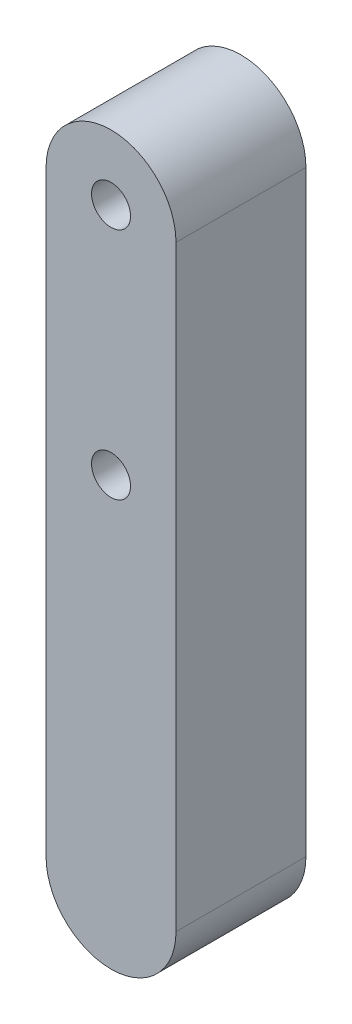
from build123d import *

# Parameters (mm, degrees)
SKETCH2_R           = 3
BOSS_EXTRUDE3_DEPTH = 20


with BuildPart() as part:
    # Sketch2 → Boss-Extrude3 (new body)
    with BuildSketch(Plane(origin=(0, 0, 0), x_dir=(-1, 0, 0), z_dir=(0, 0, -1))):
        with BuildLine():
            Line((10, 18), (10, -73.877320947))
            ThreePointArc((10, -73.877320947), (0, -83.877320947), (-10, -73.877320947))
            Line((-10, -73.877320947), (-10, 18))
            ThreePointArc((-10, 18), (0, 28), (10, 18))
        make_face()
        with Locations((0, -18)):
            Circle(SKETCH2_R, mode=Mode.SUBTRACT)
        with Locations((0, 18)):
            Circle(SKETCH2_R, mode=Mode.SUBTRACT)
    extrude(amount=BOSS_EXTRUDE3_DEPTH)


solid = part.part
